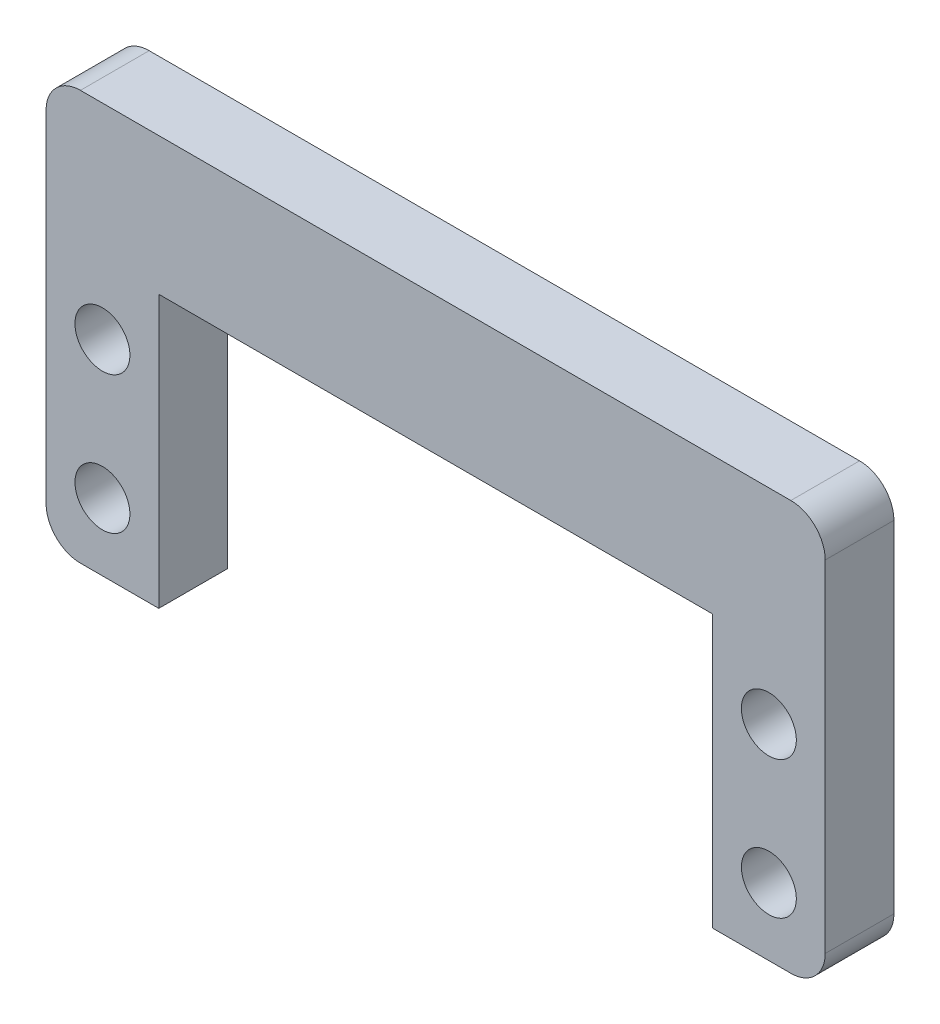
from build123d import *

# Parameters (mm, degrees)
SKETCH1_R           = 2
BOSS_EXTRUDE1_DEPTH = 5


with BuildPart() as part:
    # Sketch1 → Boss-Extrude1 (new body)
    with BuildSketch(Plane.XY):
        with BuildLine():
            ThreePointArc((-25.85, -9.9), (-27.617766953, -9.167766953), (-28.35, -7.4))
            Line((-28.35, -7.4), (-28.35, 9.9))
            Line((-28.35, 9.9), (-20.15, 9.9))
            Line((-20.15, 9.9), (-20.15, -9.9))
            Line((-20.15, -9.9), (-25.85, -9.9))
        make_face()
        with Locations((-24.25, -5)):
            Circle(SKETCH1_R, mode=Mode.SUBTRACT)
        with Locations((-24.25, 5)):
            Circle(SKETCH1_R, mode=Mode.SUBTRACT)
        with BuildLine():
            Line((-28.35, 9.9), (-20.15, 9.9))
            Line((-20.15, 9.9), (20.15, 9.9))
            Line((20.15, 9.9), (28.35, 9.9))
            Line((28.35, 9.9), (28.35, 17.4))
            ThreePointArc((28.35, 17.4), (27.617766953, 19.167766953), (25.85, 19.9))
            Line((25.85, 19.9), (-25.85, 19.9))
            ThreePointArc((-25.85, 19.9), (-27.617766953, 19.167766953), (-28.35, 17.4))
            Line((-28.35, 17.4), (-28.35, 9.9))
        make_face()
        with BuildLine():
            ThreePointArc((28.35, -7.4), (27.617766953, -9.167766953), (25.85, -9.9))
            Line((25.85, -9.9), (20.15, -9.9))
            Line((20.15, -9.9), (20.15, 9.9))
            Line((20.15, 9.9), (28.35, 9.9))
            Line((28.35, 9.9), (28.35, -7.4))
        make_face()
        with Locations((24.25, 5)):
            Circle(SKETCH1_R, mode=Mode.SUBTRACT)
        with Locations((24.25, -5)):
            Circle(SKETCH1_R, mode=Mode.SUBTRACT)
    extrude(amount=BOSS_EXTRUDE1_DEPTH)


solid = part.part
